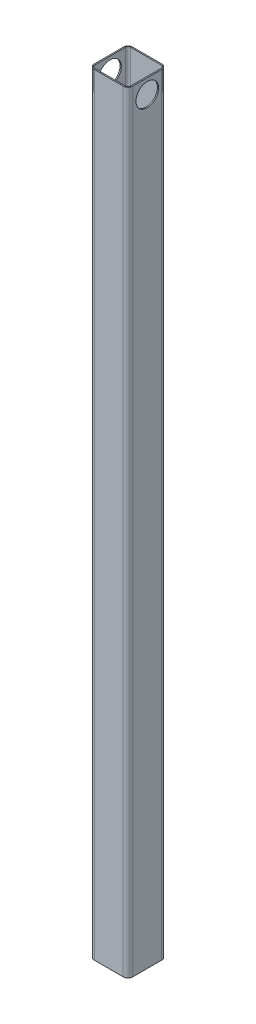
from build123d import *

# Parameters (mm, degrees)
BOSS_EXTRUDE1_DEPTH = 762
SKETCH2_R           = 22.479
CUT_EXTRUDE1_DEPTH  = 77.2


with BuildPart() as part:
    # Sketch1 → Boss-Extrude1 (new body, symmetric)
    with BuildSketch(Plane(origin=(0, 0, 0), x_dir=(1, 0, 0), z_dir=(0, 1, 0))):
        with BuildLine():
            Line((-28.575, -38.1), (28.575, -38.1))
            ThreePointArc((28.575, -38.1), (35.310192091, -35.310192091), (38.1, -28.575))
            Line((38.1, -28.575), (38.1, 28.575))
            ThreePointArc((38.1, 28.575), (35.310192091, 35.310192091), (28.575, 38.1))
            Line((28.575, 38.1), (-28.575, 38.1))
            ThreePointArc((-28.575, 38.1), (-35.310192091, 35.310192091), (-38.1, 28.575))
            Line((-38.1, 28.575), (-38.1, -28.575))
            ThreePointArc((-38.1, -28.575), (-35.310192091, -35.310192091), (-28.575, -38.1))
        make_face()
        with BuildLine():
            Line((-30.9245, -35.687), (30.9245, -35.687))
            ThreePointArc((30.9245, -35.687), (34.292096045, -34.292096045), (35.687, -30.9245))
            Line((35.687, -30.9245), (35.687, 30.9245))
            ThreePointArc((35.687, 30.9245), (34.292096045, 34.292096045), (30.9245, 35.687))
            Line((30.9245, 35.687), (-30.9245, 35.687))
            ThreePointArc((-30.9245, 35.687), (-34.292096045, 34.292096045), (-35.687, 30.9245))
            Line((-35.687, 30.9245), (-35.687, -30.9245))
            ThreePointArc((-35.687, -30.9245), (-34.292096045, -34.292096045), (-30.9245, -35.687))
        make_face(mode=Mode.SUBTRACT)
    extrude(amount=BOSS_EXTRUDE1_DEPTH, both=True)

    # Sketch2 → Cut-Extrude1 (cut, through all)
    with BuildSketch(Plane(origin=(38.1, 0, 0), x_dir=(0, 0, -1), z_dir=(1, 0, 0))):
        with Locations((0, 733.171)):
            Circle(SKETCH2_R)
    extrude(amount=-CUT_EXTRUDE1_DEPTH, mode=Mode.SUBTRACT)


solid = part.part
